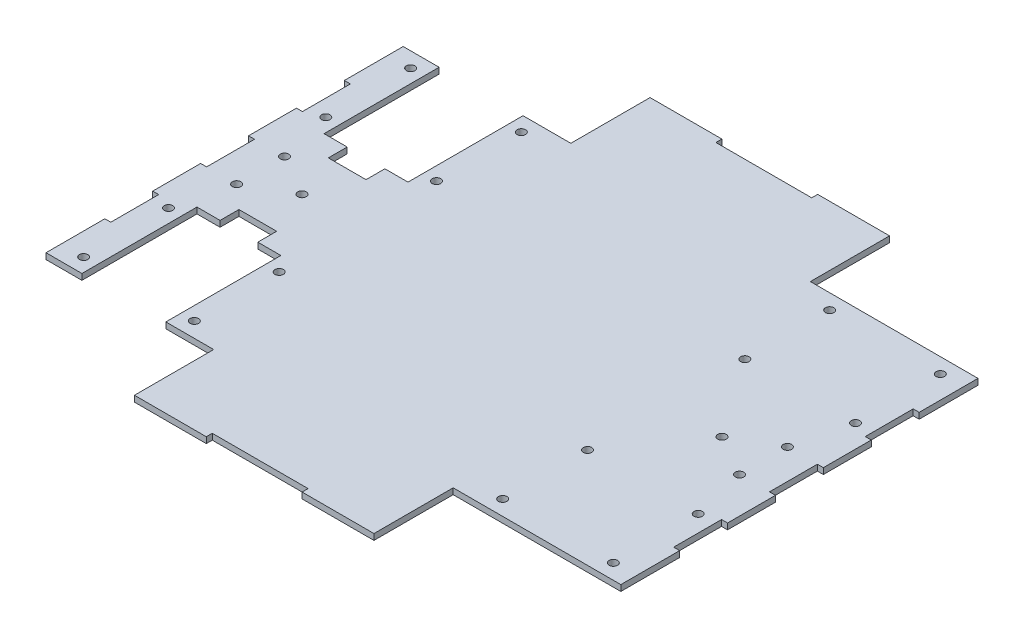
from build123d import *

# Parameters (mm, degrees)
SKETCH1_R           = 2.25
BOSS_EXTRUDE1_DEPTH = 3.175


with BuildPart() as part:
    # Sketch1 → Boss-Extrude1 (new body)
    with BuildSketch(Plane(origin=(0, 0, 0), x_dir=(1, 0, 0), z_dir=(0, 1, 0))):
        Polygon((152.4, 63.5), (152.4, 94.7), (63.5, 94.7), (63.5, 136.7), (25.4, 136.7), (25.4, 133.525), (-25.4, 133.525), (-25.4, 136.7), (-63.5, 136.7), (-63.5, 94.7), (-88.8476, 94.7), (-88.8476, 33.7), (-101.0988, 33.7), (-101.0988, 23.7), (-121.0988, 23.7), (-121.0988, 33.7), (-133.35, 33.7), (-133.35, 94.7), (-152.4, 94.7), (-152.4, 63.5), (-149.225, 63.5), (-149.225, 38.1), (-152.4, 38.1), (-152.4, 12.7), (-149.225, 12.7), (-149.225, -12.7), (-152.4, -12.7), (-152.4, -38.1), (-149.225, -38.1), (-149.225, -63.5), (-152.4, -63.5), (-152.4, -94.7), (-133.35, -94.7), (-133.35, -33.7), (-121.0988, -33.7), (-121.0988, -23.7), (-101.0988, -23.7), (-101.0988, -33.7), (-88.8476, -33.7), (-88.8476, -94.7), (-63.5, -94.7), (-63.5, -136.7), (-25.4, -136.7), (-25.4, -133.525), (25.4, -133.525), (25.4, -136.7), (63.5, -136.7), (63.5, -94.7), (152.4, -94.7), (152.4, -63.5), (149.225, -63.5), (149.225, -38.1), (152.4, -38.1), (152.4, -12.7), (149.225, -12.7), (149.225, 12.7), (152.4, 12.7), (152.4, 38.1), (149.225, 38.1), (149.225, 63.5), align=None)
        with Locations((-140.4411, -86.7)):
            Circle(SKETCH1_R, mode=Mode.SUBTRACT)
        with Locations((-81.7565, -86.7)):
            Circle(SKETCH1_R, mode=Mode.SUBTRACT)
        with Locations((-140.4411, -41.7)):
            Circle(SKETCH1_R, mode=Mode.SUBTRACT)
        with Locations((-81.7565, -41.7)):
            Circle(SKETCH1_R, mode=Mode.SUBTRACT)
        with Locations((-133.35, -12.7)):
            Circle(SKETCH1_R, mode=Mode.SUBTRACT)
        with Locations((81.7565, -86.7)):
            Circle(SKETCH1_R, mode=Mode.SUBTRACT)
        with Locations((140.4411, -86.7)):
            Circle(SKETCH1_R, mode=Mode.SUBTRACT)
        with Locations((81.7565, -41.7)):
            Circle(SKETCH1_R, mode=Mode.SUBTRACT)
        with Locations((140.4411, -41.7)):
            Circle(SKETCH1_R, mode=Mode.SUBTRACT)
        with Locations((133.35, -12.7)):
            Circle(SKETCH1_R, mode=Mode.SUBTRACT)
        with Locations((-133.35, 12.7)):
            Circle(SKETCH1_R, mode=Mode.SUBTRACT)
        with Locations((-111.352954744, 0)):
            Circle(SKETCH1_R, mode=Mode.SUBTRACT)
        with Locations((-140.4411, 41.7)):
            Circle(SKETCH1_R, mode=Mode.SUBTRACT)
        with Locations((-81.7565, 41.7)):
            Circle(SKETCH1_R, mode=Mode.SUBTRACT)
        with Locations((-140.4411, 86.7)):
            Circle(SKETCH1_R, mode=Mode.SUBTRACT)
        with Locations((-81.7565, 86.7)):
            Circle(SKETCH1_R, mode=Mode.SUBTRACT)
        with Locations((111.352954744, 0)):
            Circle(SKETCH1_R, mode=Mode.SUBTRACT)
        with Locations((133.35, 12.7)):
            Circle(SKETCH1_R, mode=Mode.SUBTRACT)
        with Locations((81.7565, 41.7)):
            Circle(SKETCH1_R, mode=Mode.SUBTRACT)
        with Locations((140.4411, 41.7)):
            Circle(SKETCH1_R, mode=Mode.SUBTRACT)
        with Locations((81.7565, 86.7)):
            Circle(SKETCH1_R, mode=Mode.SUBTRACT)
        with Locations((140.4411, 86.7)):
            Circle(SKETCH1_R, mode=Mode.SUBTRACT)
    extrude(amount=BOSS_EXTRUDE1_DEPTH)


solid = part.part
